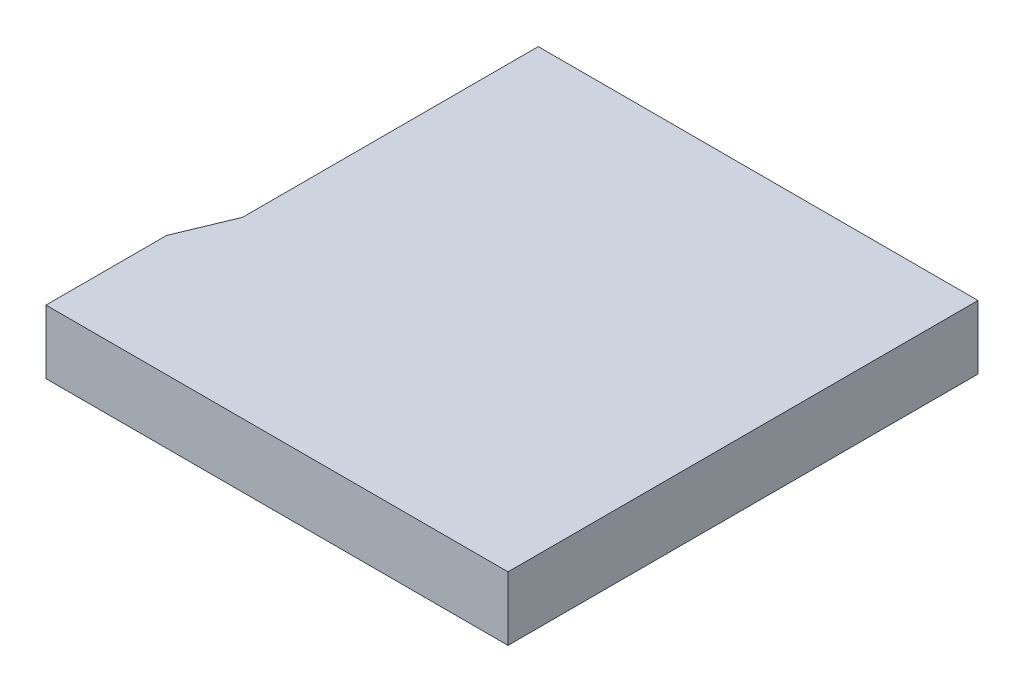
from build123d import *

# Parameters (mm, degrees)
EXTRUDE_1_DEPTH = 2


with BuildPart() as part:
    # Эскиз1 → Бобышка-Вытянуть1 (new body)
    with BuildSketch(Plane(origin=(0, 0, 0), x_dir=(1, 0, 0), z_dir=(0, 1, 0))):
        Polygon((0, 0), (14.5, 0), (14.5, 14.75), (0.699265746, 14.75), (0.699265746, 5.471068058), (0, 3.786656823), align=None)
    extrude(amount=EXTRUDE_1_DEPTH)


solid = part.part
